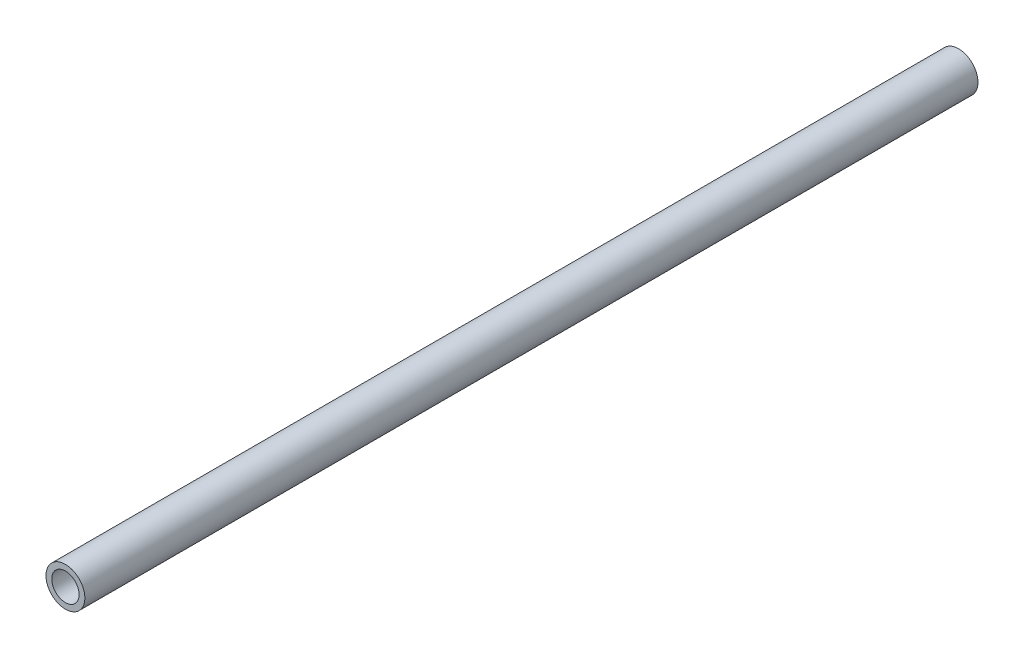
from build123d import *

# Parameters (mm, degrees)
SKETCH1_R           = 13.5
SKETCH1_R_2         = 9.5
BOSS_EXTRUDE1_DEPTH = 620


with BuildPart() as part:
    # Sketch1 → Boss-Extrude1 (new body)
    with BuildSketch(Plane.XY):
        with Locations((347.5, -20)):
            Circle(SKETCH1_R)
        with Locations((347.5, -20)):
            Circle(SKETCH1_R_2, mode=Mode.SUBTRACT)
    extrude(amount=BOSS_EXTRUDE1_DEPTH)


solid = part.part
